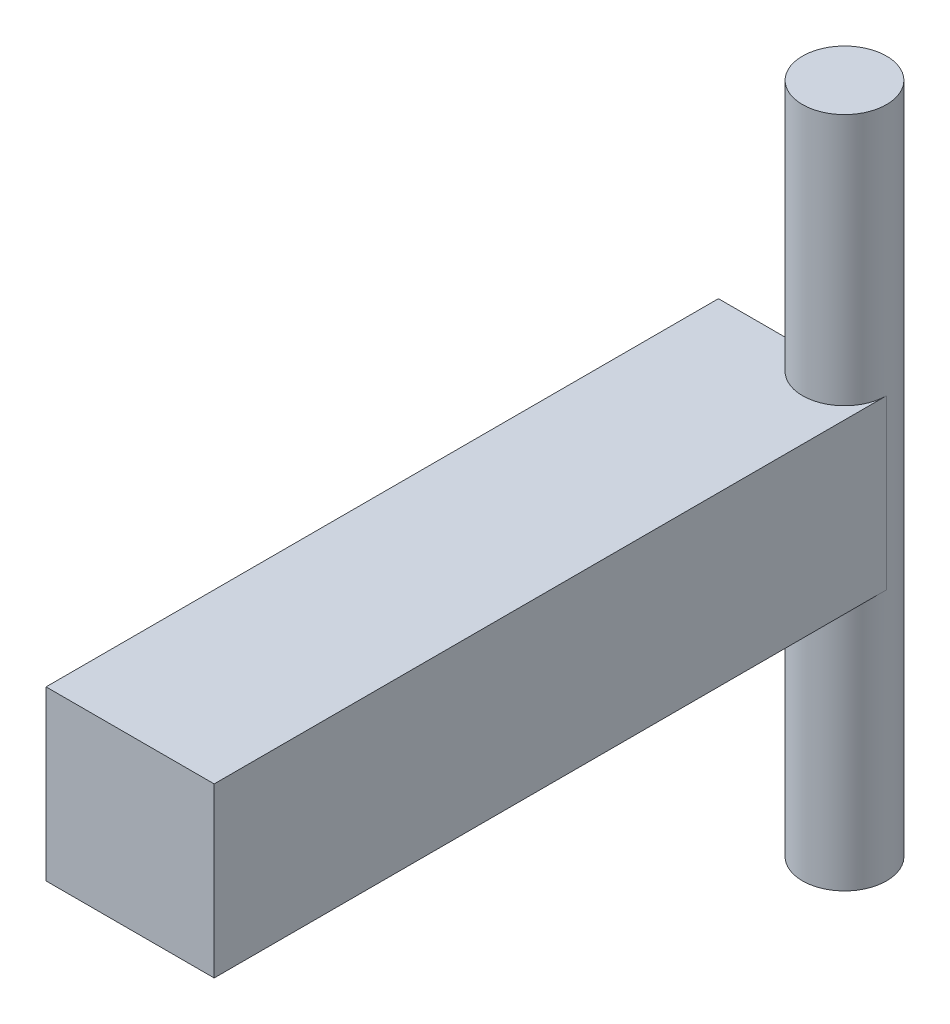
from build123d import *

# Parameters (mm, degrees)
SKETCH_1_W      = 4
SKETCH_1_H      = 4
EXTRUDE_1_DEPTH = 16
SKETCH_3_R      = 1
EXTRUDE_2_DEPTH = 8


with BuildPart() as part:
    # 草图1 → 凸台-拉伸1 (new body)
    with BuildSketch(Plane.XY):
        Rectangle(SKETCH_1_W, SKETCH_1_H)
    extrude(amount=EXTRUDE_1_DEPTH)

    # 草图3 → 凸台-拉伸2 (add, symmetric)
    with BuildSketch(Plane(origin=(0, 0, 0), x_dir=(1, 0, 0), z_dir=(0, 1, 0))):
        with Locations((1, 0)):
            Circle(SKETCH_3_R)
    extrude(amount=EXTRUDE_2_DEPTH, both=True)


solid = part.part
